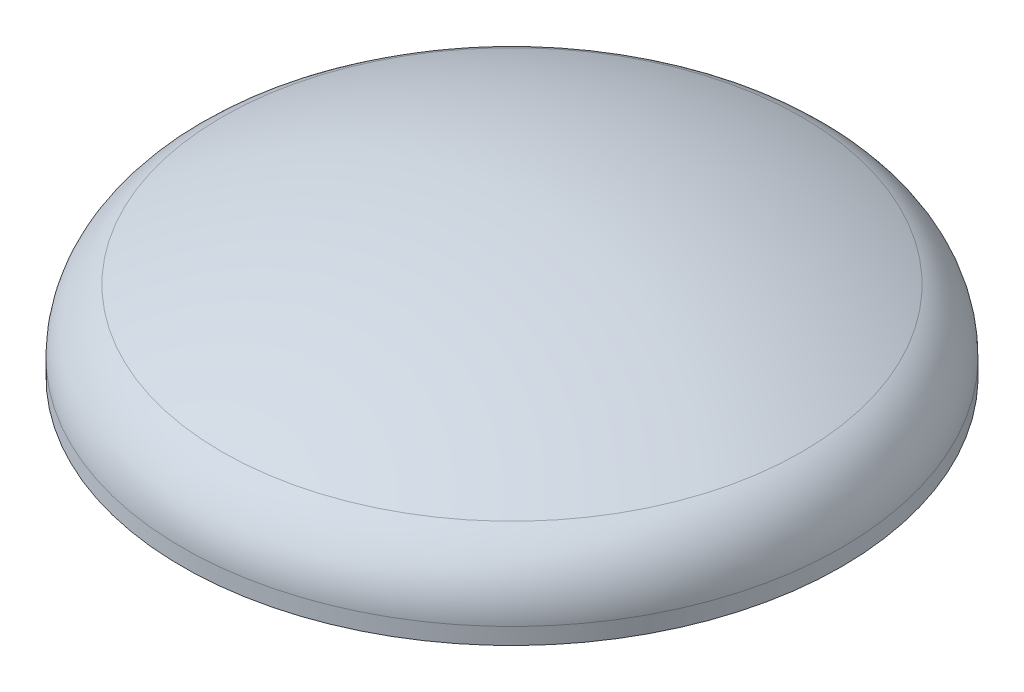
from build123d import *


with BuildPart() as part:
    # Rotationsschnitt → Klöpperboden (revolve)
    with BuildSketch(Plane.XY, mode=Mode.PRIVATE) as kl_pperboden_sk:
        with BuildLine():
            Line((-900, 0), (-900, 45))
            ThreePointArc((-900, 45), (-870.766611209, 146.810039133), (-791.972993744, 217.601570654))
            ThreePointArc((-791.972993744, 217.601570654), (-406.334858199, 353.692763685), (0, 399.84))
            Line((0, 399.84), (0, 387.84))
            ThreePointArc((0, 387.84), (-403.643898873, 341.998374521), (-786.72813948, 206.80844767))
            ThreePointArc((-786.72813948, 206.80844767), (-860.594633743, 140.443652841), (-888, 45))
            Line((-888, 45), (-888, 0))
            Line((-888, 0), (-900, 0))
        make_face()
    revolve(kl_pperboden_sk.sketch.rotate(Axis((0, 0, 0), (0, 1, 0)), 180), axis=Axis((0, 0, 0), (0, 1, 0)))  # turned: the seam where the file's is


solid = part.part
